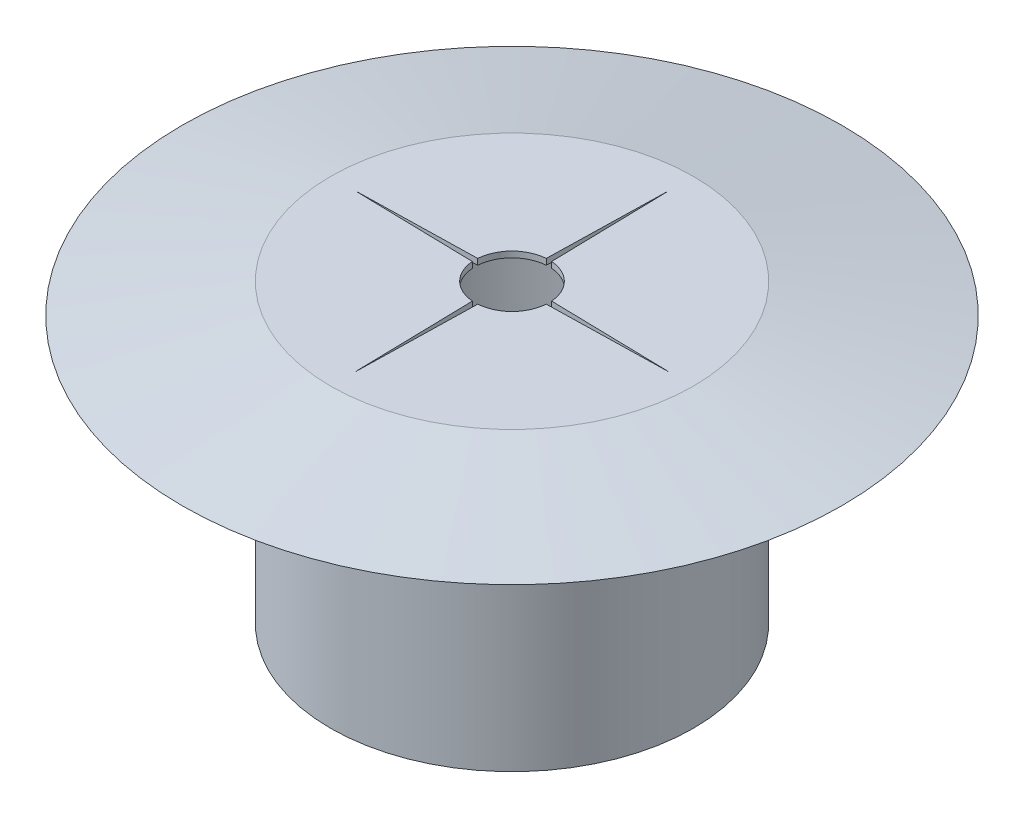
from build123d import *

# Parameters (mm, degrees)
SALIENTE_EXTRUIR2_DEPTH = 0.4


with BuildPart() as part:
    # Croquis1 → Revolución1 (revolve)
    with BuildSketch(Plane.XY):
        Polygon((-10.9, 20), (-10.9, 0), (-12.25, 0), (-12.25, 18), (-22.25, 18), (-12.25, 20), align=None)
    revolve(axis=Axis((0, 0, 0), (0, 1, 0)))

    # Croquis3 → Saliente-Extruir2 (add)
    with BuildSketch(Plane(origin=(0, 20, 0), x_dir=(1, 0, 0), z_dir=(0, 1, 0))):
        with BuildLine():
            ThreePointArc((10.9, 0), (7.707463915, -7.707463915), (0, -10.9))
            ThreePointArc((0, -10.9), (-7.707463915, -7.707463915), (-10.9, 0))
            ThreePointArc((-10.9, 0), (-7.707463915, 7.707463915), (0, 10.9))
            ThreePointArc((0, 10.9), (7.707463915, 7.707463915), (10.9, 0))
        make_face()
        with BuildLine():
            Line((0.181294315, -2.493417809), (0, -10.639817501))
            Line((0, -10.639817501), (-0.181294315, -2.493417809))
            ThreePointArc((-0.181294315, -2.493417809), (-1.767766953, -1.767766953), (-2.493417809, -0.181294315))
            Line((-2.493417809, -0.181294315), (-10.639817501, 0))
            Line((-10.639817501, 0), (-2.493417809, 0.181294315))
            ThreePointArc((-2.493417809, 0.181294315), (-1.767766953, 1.767766953), (-0.181294315, 2.493417809))
            Line((-0.181294315, 2.493417809), (0, 10.639817501))
            Line((0, 10.639817501), (0.181294315, 2.493417809))
            ThreePointArc((0.181294315, 2.493417809), (1.767766953, 1.767766953), (2.493417809, 0.181294315))
            Line((2.493417809, 0.181294315), (10.639817501, 0))
            Line((10.639817501, 0), (2.493417809, -0.181294315))
            ThreePointArc((2.493417809, -0.181294315), (1.767766953, -1.767766953), (0.181294315, -2.493417809))
        make_face(mode=Mode.SUBTRACT)
    extrude(amount=-SALIENTE_EXTRUIR2_DEPTH)


solid = part.part
